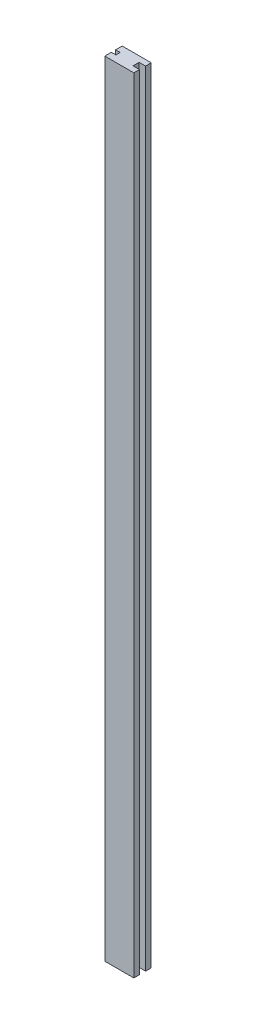
from build123d import *

# Parameters (mm, degrees)
EXTRUDE_1_DEPTH = 1350


with BuildPart() as part:
    # Эскиз1 → Бобышка-Вытянуть1 (new body)
    with BuildSketch(Plane(origin=(0, 0, 0), x_dir=(1, 0, 0), z_dir=(0, 1, 0))):
        Polygon((0, 3.657663655), (0, -3.657663655), (-7.956991175, -3.657663655), (-7.956991175, -15), (42.043008825, -15), (42.043008825, -5.25), (31, -5.25), (31, 0), (31, 5.25), (42.043008825, 5.25), (42.043008825, 15), (-7.956991175, 15), (-7.956991175, 3.657663655), align=None)
    extrude(amount=EXTRUDE_1_DEPTH)


solid = part.part
